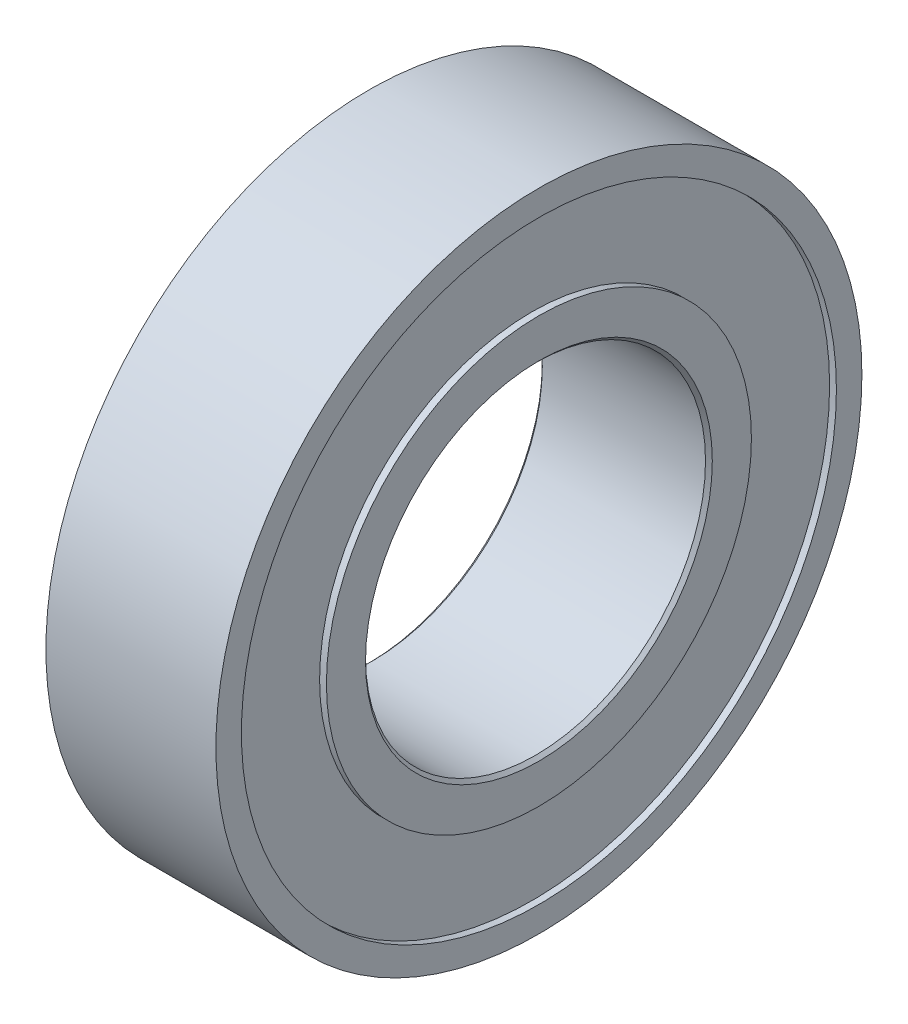
from build123d import *

# Parameters (mm, degrees)
SKETCH_1_R          = 9.5
SKETCH_1_R_2        = 5
EXTRUDE_1_DEPTH     = 5
SKETCH_2_R          = 8.25
SKETCH_2_R_2        = 6.25
CUT_EXTRUDE_1_DEPTH = 0.2
SKETCH_3_R          = 8.75
SKETCH_3_R_2        = 6.25
CUT_EXTRUDE_2_DEPTH = 0.2
CHAMFER_2_SIZE      = 0.1


with BuildPart() as part:
    # 草图1 → 凸台-拉伸1 (new body)
    with BuildSketch(Plane(origin=(0, 0, 0), x_dir=(0, 0, -1), z_dir=(1, 0, 0))):
        Circle(SKETCH_1_R)
        Circle(SKETCH_1_R_2, mode=Mode.SUBTRACT)
    extrude(amount=EXTRUDE_1_DEPTH)

    # 草图2 → 切除-拉伸1 (cut)
    with BuildSketch(Plane.ZY):
        with Locations((0.111641095, 0)):
            Circle(SKETCH_2_R)
        with Locations((0.111641095, 0)):
            Circle(SKETCH_2_R_2, mode=Mode.SUBTRACT)
    extrude(amount=-CUT_EXTRUDE_1_DEPTH, mode=Mode.SUBTRACT)

    # 草图3 → 切除-拉伸2 (cut)
    with BuildSketch(Plane(origin=(5, 0, 0), x_dir=(0, 0, -1), z_dir=(1, 0, 0))):
        Circle(SKETCH_3_R)
        Circle(SKETCH_3_R_2, mode=Mode.SUBTRACT)
    extrude(amount=-CUT_EXTRUDE_2_DEPTH, mode=Mode.SUBTRACT)

    # 倒角2
    chamfer_2_edges = [part.edges().sort_by_distance(p)[0] for p in [
        (0, 0, 5),
        (5, 0, 5),
    ]]
    chamfer(chamfer_2_edges, length=CHAMFER_2_SIZE)


solid = part.part
